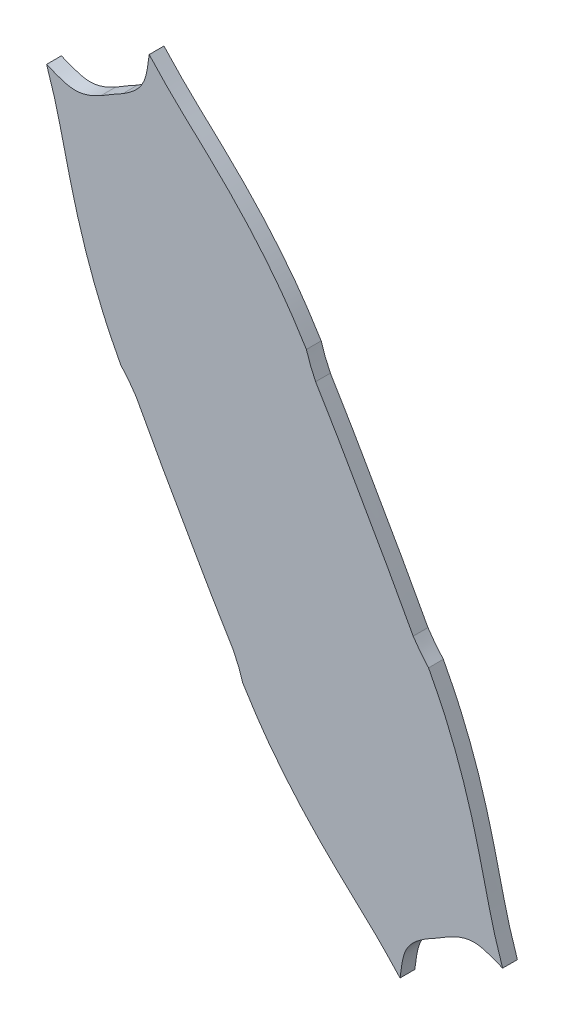
from build123d import *

# Parameters (mm, degrees)
EXTRUDE_1_DEPTH = 3


with BuildPart() as part:
    # Model → Бобышка-Вытянуть1 (new body)
    with BuildSketch(Plane.XY):
        with BuildLine():
            add(Edge.make_bspline(
                [(28.149610918, 56.207860507), (27.560922081, 51.146890819), (27.112546506, 49.376041298), (22.779757926, 46.651828213)],
                knots=[0, 0, 0, 0, 1, 1, 1, 1], degree=3))
            add(Edge.make_bspline(
                [(22.779757926, 46.651828213), (20.768921561, 45.547558815), (20.273287738, 45.259325354), (18.319069439, 44.05769969)],
                knots=[0, 0, 0, 0, 1, 1, 1, 1], degree=3))
            add(Edge.make_bspline(
                [(18.319069439, 44.05769969), (13.803279303, 41.641988188), (12.048597233, 42.126790249), (7.33961788, 44.080726925)],
                knots=[0, 0, 0, 0, 1, 1, 1, 1], degree=3))
            add(Edge.make_bspline(
                [(7.33961788, 44.080726925), (8.149699278, 41.549642577), (8.621529102, 40.179387064), (9.628519532, 36.569244705), (10.275261882, 33.842755264), (11.17343166, 30.034855536), (12.386200485, 24.898053213), (14.625548303, 17.062650929), (15.816783113, 13.461801988), (18.839691943, 5.845364354), (19.908248831, 3.52685101), (22.36744727, -1.185213105)],
                knots=[0, 0, 0, 0, 0.125, 0.125, 0.25, 0.25, 0.5, 0.5, 0.75, 0.75, 1, 1, 1, 1], degree=3))
            add(Edge.make_bspline(
                [(22.36744727, -1.185213105), (23.864896129, -2.87516102), (24.210365999, -3.320130257), (25.479686226, -5.187547479)],
                knots=[0, 0, 0, 0, 1, 1, 1, 1], degree=3))
            add(Edge.make_bspline(
                [(25.479686226, -5.187547479), (29.668288598, -13.038710968), (31.727341764, -16.552093911), (38.694819033, -28.817050656), (40.654400173, -32.387347919), (45.275114793, -39.992234686)],
                knots=[0, 0, 0, 0, 0.5, 0.5, 1, 1, 1, 1], degree=3))
            add(Edge.make_bspline(
                [(45.275114793, -39.992234686), (46.241533848, -42.044233729), (46.450109134, -42.570291399), (47.148538289, -44.728240061)],
                knots=[0, 0, 0, 0, 1, 1, 1, 1], degree=3))
            add(Edge.make_bspline(
                [(47.148538289, -44.728240061), (49.973426614, -49.272405433), (51.482586935, -51.440933032), (56.470710005, -57.829999853), (59.164176218, -60.879346353), (64.608626983, -66.529344664), (66.642517284, -68.464119623), (74.42569361, -75.69131071), (75.386253078, -76.68142814), (79.041318652, -80.589024236)],
                knots=[0, 0, 0, 0, 0.25, 0.25, 0.5, 0.5, 0.75, 0.75, 1, 1, 1, 1], degree=3))
            add(Edge.make_bspline(
                [(79.041318652, -80.589024236), (79.629599945, -75.528227661), (80.077839438, -73.757405674), (84.410276024, -71.033059032)],
                knots=[0, 0, 0, 0, 1, 1, 1, 1], degree=3))
            add(Edge.make_bspline(
                [(84.410276024, -71.033059032), (86.421198824, -69.928740939), (86.91688577, -69.640544451), (88.871337213, -68.43909049)],
                knots=[0, 0, 0, 0, 1, 1, 1, 1], degree=3))
            add(Edge.make_bspline(
                [(88.871337213, -68.43909049), (93.386975511, -66.022642512), (95.141867274, -66.507429453), (99.851301684, -68.460878088)],
                knots=[0, 0, 0, 0, 1, 1, 1, 1], degree=3))
            add(Edge.make_bspline(
                [(99.851301684, -68.460878088), (99.040925268, -65.929940052), (98.568960988, -64.559806075), (97.561674354, -60.949723571), (96.916130588, -58.2289141), (96.013894102, -54.404458492), (94.803674048, -49.278915964), (92.564269255, -41.443620041), (91.373036556, -37.842869648), (88.350151427, -30.226605543), (87.281558663, -27.908155461), (84.822527009, -23.196115705)],
                knots=[0, 0, 0, 0, 0.125, 0.125, 0.25, 0.25, 0.5, 0.5, 0.75, 0.75, 1, 1, 1, 1], degree=3))
            add(Edge.make_bspline(
                [(84.822527009, -23.196115705), (83.325122862, -21.506034699), (82.979667426, -21.061032084), (81.710402424, -19.193487861)],
                knots=[0, 0, 0, 0, 1, 1, 1, 1], degree=3))
            add(Edge.make_bspline(
                [(81.710402424, -19.193487861), (77.522252219, -11.342279926), (75.588524574, -8.050461965), (68.369510384, 4.656701124), (66.533556444, 8.004368796), (61.915420371, 15.610629705)],
                knots=[0, 0, 0, 0, 0.5, 0.5, 1, 1, 1, 1], degree=3))
            add(Edge.make_bspline(
                [(61.915420371, 15.610629705), (60.949423407, 17.663222472), (60.740864542, 18.189405403), (60.042133095, 20.347645644)],
                knots=[0, 0, 0, 0, 1, 1, 1, 1], degree=3))
            add(Edge.make_bspline(
                [(60.042133095, 20.347645644), (57.216954414, 24.891531729), (55.707611925, 27.059818341), (50.719279832, 33.448684897), (48.025845314, 36.497947024), (42.581538922, 42.147819434), (40.545819203, 44.084319784), (32.766687748, 51.308192561), (31.804324389, 52.300050246), (28.149610918, 56.207860507)],
                knots=[0, 0, 0, 0, 0.25, 0.25, 0.5, 0.5, 0.75, 0.75, 1, 1, 1, 1], degree=3))
        make_face()
    extrude(amount=EXTRUDE_1_DEPTH)


solid = part.part
